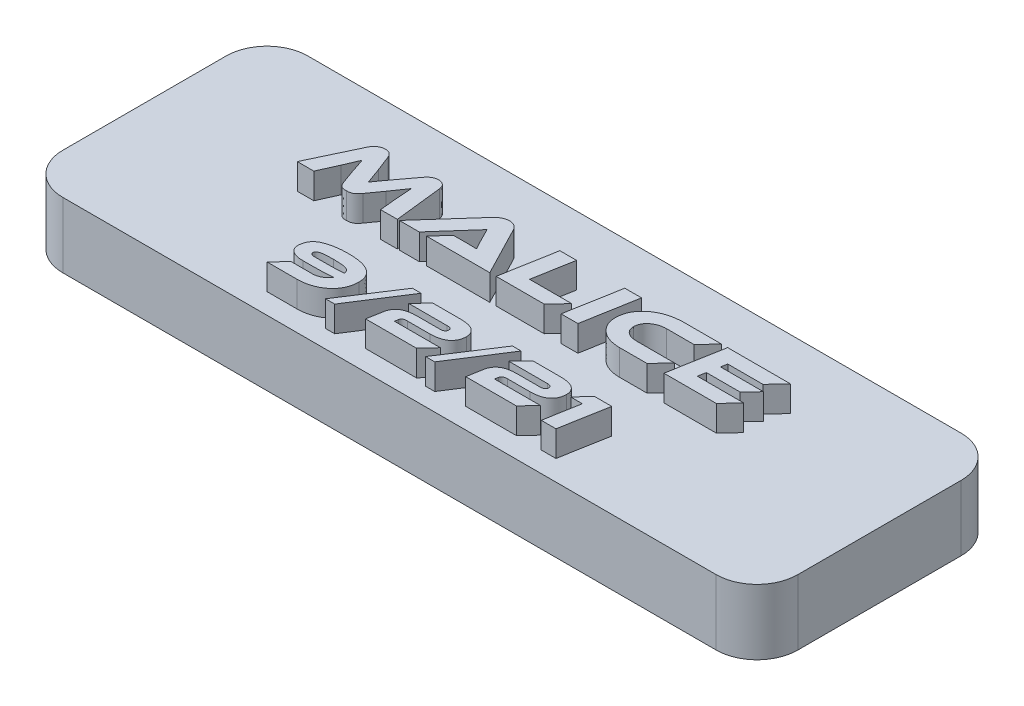
from build123d import *

# Parameters (mm, degrees)
SKETCH1_W           = 57.15
SKETCH1_H           = 19.05
BOSS_EXTRUDE1_DEPTH = 5.08
FILLET1_R           = 3.175
BOSS_EXTRUDE2_DEPTH = 2
SKETCH4_R           = 0.9
CUT_EXTRUDE1_DEPTH  = 4


with BuildPart() as part:
    # Sketch1 → Boss-Extrude1 (new body)
    with BuildSketch(Plane(origin=(0, 0, 0), x_dir=(1, 0, 0), z_dir=(0, 1, 0))):
        Rectangle(SKETCH1_W, SKETCH1_H)
    extrude(amount=BOSS_EXTRUDE1_DEPTH)

    # Fillet1
    fillet1_edges = [part.edges().sort_by_distance(p)[0] for p in [
        (-28.575, 2.54, -9.525),
        (-28.575, 2.54, 9.525),
        (28.575, 2.54, 9.525),
        (28.575, 2.54, -9.525),
    ]]
    fillet(fillet1_edges, radius=FILLET1_R)

    # Sketch3 → Boss-Extrude2 (add)
    with BuildSketch(Plane(origin=(0, 5.08, 0), x_dir=(1, 0, 0), z_dir=(0, 1, 0))):
        Polygon((13.310588964, 1.105536066), (13.411688748, 1.700326644), (16.015008189, 1.700326644), (16.924906246, 2.629107706), (13.582294634, 2.629107706), (13.670756945, 3.106887389), (16.406769853, 3.106887389), (17.449361376, 4.206347541), (12.55865932, 4.206347541), (11.806729675, 0.006075914), (15.875995986, 0.006075914), (16.912268773, 1.105536066), align=None)
        with BuildLine():
            add(Edge.make_bspline(
                [(8.559459744, 1.105536066), (8.519738714, 1.106368572), (8.442323233, 1.107991107), (8.329496145, 1.120099472), (8.223251152, 1.139341634), (8.122839563, 1.164731953), (8.028306652, 1.197730851), (7.93979656, 1.237674392), (7.857498969, 1.284870974), (7.781693666, 1.338214411), (7.714222428, 1.398892985), (7.654237259, 1.463686553), (7.603479599, 1.534061863), (7.560995817, 1.609307897), (7.528158823, 1.690172386), (7.504347011, 1.775740301), (7.48957339, 1.866215268), (7.486613584, 1.928202108), (7.485097778, 1.95994744)],
                knots=[0, 0, 0, 0, 0.000119146, 0.000232213, 0.000339979, 0.000442857, 0.0005426, 0.00063997, 0.000733741, 0.000826832, 0.000917476, 0.001005473, 0.001091233, 0.001177183, 0.0012641, 0.001352376, 0.001443149, 0.001538437, 0.001538437, 0.001538437, 0.001538437], degree=3))
            add(Edge.make_bspline(
                [(7.485097778, 1.95994744), (7.487475399, 2.00089212), (7.492159335, 2.08155355), (7.515918687, 2.199187811), (7.550399554, 2.311187764), (7.597375995, 2.41754111), (7.657504595, 2.517456178), (7.728928863, 2.612420697), (7.81409989, 2.700160835), (7.909460035, 2.782047564), (8.014487165, 2.855559397), (8.125969662, 2.920673089), (8.243882568, 2.975739929), (8.367493329, 3.021270473), (8.496953977, 3.058247704), (8.632457582, 3.084423964), (8.773965573, 3.10108536), (8.870301574, 3.104537604), (8.919406329, 3.106297295)],
                knots=[0, 0, 0, 0, 0.000122909, 0.000242131, 0.000358943, 0.000473945, 0.00058996, 0.00070807, 0.000829622, 0.000956043, 0.00108463, 0.001213669, 0.001342898, 0.001474501, 0.001608483, 0.001746351, 0.001888089, 0.00203545, 0.00203545, 0.00203545, 0.00203545], degree=3))
            Line((8.919406329, 3.106297295), (11.042723192, 3.106887389))
            Line((11.042723192, 3.106887389), (12.078995979, 4.206347541))
            Line((12.078995979, 4.206347541), (9.115508557, 4.206347541))
            add(Edge.make_bspline(
                [(9.115508557, 4.206347541), (9.013488767, 4.202700375), (8.813680891, 4.195557324), (8.520464977, 4.162353327), (8.240327871, 4.110015155), (7.973466922, 4.036172143), (7.718858162, 3.945267581), (7.477731511, 3.833094278), (7.249090222, 3.702119343), (7.070177689, 3.576781715), (6.934643749, 3.469194079), (6.840566124, 3.383435035), (6.751736583, 3.295964452), (6.668937448, 3.205335074), (6.593434551, 3.110727377), (6.522248768, 3.01426649), (6.459710324, 2.913020304), (6.401543861, 2.809716549), (6.350348537, 2.702914965), (6.306505274, 2.592415367), (6.268346866, 2.479140843), (6.23480376, 2.363167205), (6.209843716, 2.243547853), (6.189145543, 2.121372678), (6.176710882, 1.99550854), (6.17261647, 1.910604524), (6.170543478, 1.867617826)],
                knots=[0, 0, 0, 0, 0.000306166, 0.000599632, 0.000884344, 0.001160233, 0.001429449, 0.00169448, 0.001956971, 0.002218938, 0.002348999, 0.002475859, 0.002600617, 0.002722926, 0.00284385, 0.002963619, 0.003082322, 0.003200591, 0.003319167, 0.003437316, 0.003556997, 0.003677669, 0.003799234, 0.003923371, 0.004049262, 0.004178365, 0.004178365, 0.004178365, 0.004178365], degree=3))
            add(Edge.make_bspline(
                [(6.170543478, 1.867617826), (6.173543352, 1.801688472), (6.179448311, 1.671912941), (6.209898818, 1.482185543), (6.258551934, 1.301387781), (6.325358212, 1.130003576), (6.41036649, 0.967607666), (6.512900539, 0.814264123), (6.635152795, 0.671011828), (6.773384063, 0.536982875), (6.927640568, 0.415938203), (7.095199959, 0.308972587), (7.275905833, 0.218224767), (7.470135736, 0.144692398), (7.676305614, 0.084618858), (7.896140514, 0.042789332), (8.128208749, 0.013380635), (8.287632001, 0.00815489), (8.369085266, 0.005484928)],
                knots=[0, 0, 0, 0, 0.000197872, 0.000389491, 0.000575101, 0.000758611, 0.000940158, 0.001123976, 0.001310786, 0.001504088, 0.001700684, 0.001897981, 0.00209953, 0.002306142, 0.002520237, 0.002742905, 0.002976823, 0.003221191, 0.003221191, 0.003221191, 0.003221191], degree=3))
            Line((8.369085266, 0.005484928), (10.492993116, 0.006075914))
            Line((10.492993116, 0.006075914), (11.522947166, 1.105536066))
            Line((11.522947166, 1.105536066), (8.559459744, 1.105536066))
        make_face()
        Polygon((5.86396781, 4.208766837), (4.56230809, 4.208766837), (3.810378445, 0.003655726), (5.118356902, 0.003655726), align=None)
        Polygon((0.257455928, 1.105536066), (0.813504741, 4.208766837), (-0.48815498, 4.208766837), (-1.240084624, 0.006075914), (2.494288652, 0.006075914), (3.536880175, 1.105536066), align=None)
        with BuildLine():
            Line((-1.732130117, 0.006075914), (-3.697257171, 3.800574494))
            add(Edge.make_bspline(
                [(-3.697257171, 3.800574494), (-3.715378115, 3.832806008), (-3.751336779, 3.896765269), (-3.816210468, 3.985575321), (-3.893469955, 4.0630874), (-3.978372867, 4.133983071), (-4.076178761, 4.192399523), (-4.18828991, 4.23493807), (-4.314331738, 4.260058315), (-4.403062671, 4.264204191), (-4.449190386, 4.266359469)],
                knots=[0, 0, 0, 0, 0.000110886, 0.000220038, 0.000328642, 0.000438436, 0.000551159, 0.000668641, 0.000796469, 0.000934872, 0.000934872, 0.000934872, 0.000934872], degree=3))
            add(Edge.make_bspline(
                [(-4.449190386, 4.266359469), (-4.499002046, 4.264009128), (-4.595733167, 4.259444915), (-4.735771923, 4.230967468), (-4.866050485, 4.187726952), (-4.98578536, 4.126959855), (-5.095467016, 4.055096369), (-5.198668369, 3.977511138), (-5.292974582, 3.892229282), (-5.350357085, 3.830720556), (-5.378885604, 3.800140628)],
                knots=[0, 0, 0, 0, 0.00014941, 0.000290146, 0.000427171, 0.000560039, 0.000691642, 0.000820174, 0.000947034, 0.001072464, 0.001072464, 0.001072464, 0.001072464], degree=3))
            Line((-5.378885604, 3.800140628), (-8.76488385, 0.006075914))
            Line((-8.76488385, 0.006075914), (-7.216793406, 0.006075914))
            Line((-7.216793406, 0.006075914), (-4.739848695, 2.798493231))
            Line((-4.739848695, 2.798493231), (-4.177481146, 1.696826253))
            add(Edge.make_bspline(
                [(-4.177481146, 1.696826253), (-4.150807141, 1.644325557), (-4.096290894, 1.5370248), (-4.026862553, 1.403208105), (-3.970779459, 1.297464771), (-3.929638344, 1.223921613), (-3.893234503, 1.155498073), (-3.867936197, 1.112747401), (-3.855904058, 1.092414734)],
                knots=[0, 0, 0, 0, 0.000176664, 0.000361065, 0.000452265, 0.000535729, 0.000613867, 0.000684736, 0.000684736, 0.000684736, 0.000684736], degree=3))
            add(Edge.make_bspline(
                [(-3.855904058, 1.092414734), (-3.911352403, 1.095166522), (-4.029512238, 1.101030553), (-4.213942773, 1.103502684), (-4.408961639, 1.10564963), (-4.541214236, 1.105358474), (-4.60733913, 1.105212899)],
                knots=[0, 0, 0, 0, 0.000166537, 0.000354888, 0.000553268, 0.00075164, 0.00075164, 0.00075164, 0.00075164], degree=3))
            Line((-4.60733913, 1.105212899), (-5.662384225, 1.105536066))
            Line((-5.662384225, 1.105536066), (-6.64810712, 0.006075914))
            Line((-6.64810712, 0.006075914), (-1.732130117, 0.006075914))
        make_face()
        with BuildLine():
            add(Edge.make_bspline(
                [(-13.467536095, 3.821864298), (-13.481567467, 3.854947842), (-13.509019866, 3.919675843), (-13.563316131, 4.00785825), (-13.626848062, 4.084680144), (-13.699918016, 4.150072297), (-13.784786564, 4.202261522), (-13.881643932, 4.239681634), (-13.990489049, 4.261491707), (-14.066604539, 4.264690453), (-14.106319469, 4.266359469)],
                knots=[0, 0, 0, 0, 0.000107692, 0.0002107, 0.00030937, 0.000405859, 0.000503537, 0.000606581, 0.000715765, 0.000834889, 0.000834889, 0.000834889, 0.000834889], degree=3))
            add(Edge.make_bspline(
                [(-14.106319469, 4.266359469), (-14.147598246, 4.264911976), (-14.230109548, 4.262018611), (-14.351874754, 4.234270285), (-14.470276706, 4.188827027), (-14.584268314, 4.125361681), (-14.693404782, 4.045413244), (-14.79022222, 3.943118147), (-14.880285745, 3.825335584), (-14.928160308, 3.735707046), (-14.952826618, 3.689527923)],
                knots=[0, 0, 0, 0, 0.000123685, 0.000247231, 0.000372524, 0.000503046, 0.00063761, 0.000776601, 0.000924145, 0.00108096, 0.00108096, 0.00108096, 0.00108096], degree=3))
            Line((-14.952826618, 3.689527923), (-16.69641045, 0.003655726))
            Line((-16.69641045, 0.003655726), (-15.413706939, 0.003655726))
            Line((-15.413706939, 0.003655726), (-14.756558342, 1.464481009))
            add(Edge.make_bspline(
                [(-14.756558342, 1.464481009), (-14.732328584, 1.519909601), (-14.684700559, 1.628864646), (-14.615829165, 1.789446184), (-14.548558078, 1.942964846), (-14.485802871, 2.090413825), (-14.425225209, 2.230959426), (-14.368533112, 2.365338229), (-14.315652855, 2.493505747), (-14.281234059, 2.576699716), (-14.264468213, 2.617224589)],
                knots=[0, 0, 0, 0, 0.000181479, 0.000356729, 0.00052418, 0.000684305, 0.000837469, 0.000983313, 0.001121843, 0.001253412, 0.001253412, 0.001253412, 0.001253412], degree=3))
            add(Edge.make_bspline(
                [(-14.264468213, 2.617224589), (-14.254223496, 2.582146896), (-14.232980976, 2.509412955), (-14.197608459, 2.396952832), (-14.1608843, 2.276154433), (-14.11754915, 2.146346616), (-14.069664633, 2.002632754), (-14.013586346, 1.841123618), (-13.948445598, 1.659810645), (-13.902744775, 1.531826555), (-13.878694976, 1.464475652)],
                knots=[0, 0, 0, 0, 0.000109626, 0.000227311, 0.000353666, 0.000488379, 0.000637834, 0.000808115, 0.001001264, 0.001215812, 0.001215812, 0.001215812, 0.001215812], degree=3))
            Line((-13.878694976, 1.464475652), (-13.499129777, 0.404912456))
            add(Edge.make_bspline(
                [(-13.499129777, 0.404912456), (-13.480955071, 0.359535583), (-13.446999655, 0.27475894), (-13.381034656, 0.165066891), (-13.309736025, 0.079389949), (-13.228674603, 0.020148619), (-13.140153659, -0.017188774), (-13.044819996, -0.042938659), (-12.940255221, -0.056575195), (-12.867674832, -0.05604004), (-12.830159662, -0.05576343)],
                knots=[0, 0, 0, 0, 0.000146435, 0.000273581, 0.000382454, 0.000478632, 0.000571543, 0.000669118, 0.00077423, 0.000886686, 0.000886686, 0.000886686, 0.000886686], degree=3))
            add(Edge.make_bspline(
                [(-12.830159662, -0.05576343), (-12.79234346, -0.055992745), (-12.717953486, -0.056443841), (-12.608524296, -0.042717291), (-12.504410842, -0.015563104), (-12.40234571, 0.022829401), (-12.301161744, 0.083036928), (-12.199938757, 0.169070984), (-12.095485911, 0.280708265), (-12.030314945, 0.367692811), (-11.995536522, 0.414112029)],
                knots=[0, 0, 0, 0, 0.00011337, 0.000223015, 0.000329662, 0.000435594, 0.000549104, 0.000680897, 0.00083287, 0.001006773, 0.001006773, 0.001006773, 0.001006773], degree=3))
            Line((-11.995536522, 0.414112029), (-11.243340844, 1.465200548))
            add(Edge.make_bspline(
                [(-11.243340844, 1.465200548), (-11.197158545, 1.529169794), (-11.108760313, 1.651614289), (-10.983975191, 1.828381807), (-10.87026189, 1.987679293), (-10.769702216, 2.133154937), (-10.677873961, 2.266547935), (-10.593187076, 2.390994455), (-10.515053641, 2.508743118), (-10.465493601, 2.584889894), (-10.44147372, 2.621795362)],
                knots=[0, 0, 0, 0, 0.000236691, 0.000453055, 0.000649121, 0.000823842, 0.000983589, 0.001134958, 0.00127542, 0.001407521, 0.001407521, 0.001407521, 0.001407521], degree=3))
            add(Edge.make_bspline(
                [(-10.44147372, 2.621795362), (-10.439239748, 2.536757041), (-10.434648993, 2.362005428), (-10.420608478, 2.139966033), (-10.407941006, 1.952236415), (-10.394363366, 1.800289613), (-10.381181024, 1.638717755), (-10.370888112, 1.52784762), (-10.365598889, 1.470874734)],
                knots=[0, 0, 0, 0, 0.000255182, 0.000524392, 0.000667354, 0.000819643, 0.000982028, 0.00115368, 0.00115368, 0.00115368, 0.00115368], degree=3))
            Line((-10.365598889, 1.470874734), (-10.21970553, 0.003655726))
            Line((-10.21970553, 0.003655726), (-8.918045809, 0.003655726))
            Line((-8.918045809, 0.003655726), (-9.335082419, 3.690201933))
            add(Edge.make_bspline(
                [(-9.335082419, 3.690201933), (-9.342447817, 3.735767572), (-9.3565213, 3.822832418), (-9.401368118, 3.942054526), (-9.460350308, 4.044898175), (-9.539381431, 4.125995793), (-9.629654398, 4.189905999), (-9.731208732, 4.235155569), (-9.843090231, 4.262540065), (-9.921157798, 4.265057293), (-9.96154256, 4.266359469)],
                knots=[0, 0, 0, 0, 0.000138154, 0.000263979, 0.000379994, 0.000491206, 0.000600771, 0.000710019, 0.000822876, 0.000943824, 0.000943824, 0.000943824, 0.000943824], degree=3))
            add(Edge.make_bspline(
                [(-9.96154256, 4.266359469), (-10.003388066, 4.264315029), (-10.085262157, 4.26031492), (-10.204189641, 4.237458819), (-10.315093823, 4.198932407), (-10.417114704, 4.144580626), (-10.512700273, 4.0797862), (-10.600183003, 4.002630646), (-10.683891156, 3.917859546), (-10.732264048, 3.853756483), (-10.756857053, 3.821166184)],
                knots=[0, 0, 0, 0, 0.000125572, 0.000245692, 0.000361916, 0.000476404, 0.000591519, 0.00070753, 0.000825838, 0.000948192, 0.000948192, 0.000948192, 0.000948192], degree=3))
            Line((-10.756857053, 3.821166184), (-11.647739981, 2.63063338))
            add(Edge.make_bspline(
                [(-11.647739981, 2.63063338), (-11.676832204, 2.592038973), (-11.733437576, 2.516944994), (-11.81579065, 2.40752977), (-11.892319929, 2.303579542), (-11.965872566, 2.207146967), (-12.033610423, 2.115786728), (-12.095293615, 2.029366729), (-12.154034616, 1.950451781), (-12.22360065, 1.854220433), (-12.303480982, 1.742020151), (-12.392133912, 1.614517972), (-12.471621427, 1.49522478), (-12.5218235, 1.418793145), (-12.545857585, 1.382201739)],
                knots=[0, 0, 0, 0, 0.000144993, 0.000282116, 0.00041083, 0.000532231, 0.000645954, 0.000752012, 0.000850745, 0.000941075, 0.001108235, 0.001263934, 0.001406932, 0.001538268, 0.001538268, 0.001538268, 0.001538268], degree=3))
            add(Edge.make_bspline(
                [(-12.545857585, 1.382201739), (-12.557934897, 1.418805813), (-12.583660775, 1.496776135), (-12.626893043, 1.619692211), (-12.675221374, 1.756361741), (-12.730447309, 1.906038253), (-12.790476038, 2.069898911), (-12.857396403, 2.24675863), (-12.929521666, 2.43736016), (-12.98029604, 2.568503977), (-13.006591498, 2.636421836)],
                knots=[0, 0, 0, 0, 0.000115632, 0.000246309, 0.000390878, 0.000550518, 0.00072492, 0.000914406, 0.001117803, 0.001336294, 0.001336294, 0.001336294, 0.001336294], degree=3))
            Line((-13.006591498, 2.636421836), (-13.467536095, 3.821864298))
        make_face()
        Polygon((9.787635139, -5.218973535), (10.688844934, -5.218973535), (10.207831117, -7.93430124), (11.352312267, -7.93430124), (12.010250706, -4.256945902), (10.655671567, -4.256945902), align=None)
        with BuildLine():
            Line((4.971026026, -5.218973535), (7.96215792, -5.218973535))
            add(Edge.make_bspline(
                [(7.96215792, -5.218973535), (7.989858834, -5.218922741), (8.041705209, -5.218827674), (8.114434212, -5.225918073), (8.175958254, -5.242216387), (8.22778879, -5.26353583), (8.26788218, -5.294908436), (8.296196179, -5.334273792), (8.313748157, -5.381008794), (8.314972856, -5.4147712), (8.315607222, -5.432259348)],
                knots=[0, 0, 0, 0, 8.3099e-05, 0.000155531, 0.000218392, 0.000273538, 0.000322508, 0.000368908, 0.000417497, 0.000469711, 0.000469711, 0.000469711, 0.000469711], degree=3))
            add(Edge.make_bspline(
                [(8.315607222, -5.432259348), (8.314967429, -5.458018948), (8.313757824, -5.506720508), (8.293195439, -5.573936821), (8.259909062, -5.630194031), (8.210695439, -5.673414306), (8.14716434, -5.704561408), (8.069430174, -5.726311626), (7.976305014, -5.738498194), (7.90930337, -5.73961472), (7.87327067, -5.740215175)],
                knots=[0, 0, 0, 0, 7.6993e-05, 0.000145564, 0.000208395, 0.000270703, 0.000339032, 0.00041902, 0.000511893, 0.000619952, 0.000619952, 0.000619952, 0.000619952], degree=3))
            Line((7.87327067, -5.740215175), (6.115507176, -5.739416071))
            add(Edge.make_bspline(
                [(6.115507176, -5.739416071), (6.05990502, -5.740560639), (5.951651858, -5.742789025), (5.793656532, -5.753609346), (5.644937172, -5.772857955), (5.505314304, -5.798779792), (5.375051106, -5.833149331), (5.253972254, -5.875619954), (5.141704874, -5.92500466), (5.038503006, -5.98174212), (4.945033809, -6.047028209), (4.860508316, -6.120143527), (4.785107707, -6.201107035), (4.719106685, -6.289606037), (4.662725112, -6.385733808), (4.615629357, -6.489539314), (4.576681994, -6.600822081), (4.559360318, -6.678800473), (4.550547277, -6.718474855)],
                knots=[0, 0, 0, 0, 0.000166829, 0.000324804, 0.000474816, 0.000616477, 0.000750546, 0.000878553, 0.001001026, 0.001118108, 0.001231277, 0.001342418, 0.001452782, 0.001562526, 0.00167296, 0.001786425, 0.001904052, 0.002025887, 0.002025887, 0.002025887, 0.002025887], degree=3))
            Line((4.550547277, -6.718474855), (4.335203165, -7.932183575))
            Line((4.335203165, -7.932183575), (8.271776009, -7.932183575))
            Line((8.271776009, -7.932183575), (9.178514698, -6.970155942))
            Line((9.178514698, -6.970155942), (5.606848887, -6.970155942))
            Line((5.606848887, -6.970155942), (5.656608937, -6.707239748))
            add(Edge.make_bspline(
                [(5.656608937, -6.707239748), (5.660386461, -6.686112106), (5.667709218, -6.645156023), (5.696420571, -6.590591717), (5.734781264, -6.543848716), (5.786120596, -6.508043577), (5.847196062, -6.47963759), (5.919513682, -6.461031101), (6.002577104, -6.450993538), (6.061500614, -6.450679637), (6.092726069, -6.450513291)],
                knots=[0, 0, 0, 0, 6.4036e-05, 0.000124134, 0.000182613, 0.000243892, 0.000310094, 0.000383827, 0.000466868, 0.000560486, 0.000560486, 0.000560486, 0.000560486], degree=3))
            Line((6.092726069, -6.450513291), (7.851580032, -6.449714187))
            add(Edge.make_bspline(
                [(7.851580032, -6.449714187), (7.917261057, -6.448593152), (8.044595497, -6.446419826), (8.228493346, -6.426694059), (8.399909956, -6.400940141), (8.557756843, -6.361961645), (8.703510836, -6.315052912), (8.834852091, -6.255202462), (8.954325207, -6.187512089), (9.059037646, -6.107690588), (9.151620838, -6.020066732), (9.2320772, -5.925525662), (9.299856084, -5.823724541), (9.355608886, -5.715194429), (9.397744856, -5.599220599), (9.428440292, -5.476792913), (9.446095637, -5.347458364), (9.44804859, -5.259004345), (9.449044644, -5.21389067)],
                knots=[0, 0, 0, 0, 0.00019697, 0.000381861, 0.000554393, 0.000716581, 0.000869107, 0.001013024, 0.00114885, 0.001280192, 0.001406932, 0.001530654, 0.001651783, 0.001773055, 0.001895792, 0.002021116, 0.002151095, 0.002286391, 0.002286391, 0.002286391, 0.002286391], degree=3))
            add(Edge.make_bspline(
                [(9.449044644, -5.21389067), (9.448592189, -5.1780961), (9.447706444, -5.108023129), (9.431496597, -5.005989197), (9.407504524, -4.909275966), (9.370969821, -4.818686266), (9.323335469, -4.734234215), (9.265256427, -4.655338408), (9.1968888, -4.582231577), (9.11759436, -4.515185386), (9.026771443, -4.455053695), (8.923192822, -4.402688892), (8.806959702, -4.359688685), (8.678772223, -4.322394884), (8.537969214, -4.294289614), (8.384622168, -4.27367202), (8.218755637, -4.26108405), (8.103926021, -4.258543735), (8.044446117, -4.257227893)],
                knots=[0, 0, 0, 0, 0.000107259, 0.000209975, 0.000309113, 0.00040566, 0.000501999, 0.00059927, 0.000698874, 0.0008016, 0.000910084, 0.001024914, 0.001148961, 0.001281358, 0.001425053, 0.00157924, 0.00174531, 0.001923772, 0.001923772, 0.001923772, 0.001923772], degree=3))
            Line((8.044446117, -4.257227893), (5.877764715, -4.256945902))
            Line((5.877764715, -4.256945902), (4.971026026, -5.218973535))
        make_face()
        Polygon((4.085215586, -4.05005839), (1.420288464, -8.139071868), (2.133515847, -8.139071868), (4.759740708, -4.05005839), align=None)
        with BuildLine():
            Line((-2.810257838, -5.218973535), (0.180874056, -5.218973535))
            add(Edge.make_bspline(
                [(0.180874056, -5.218973535), (0.20857497, -5.218922741), (0.260421344, -5.218827674), (0.333150347, -5.225918073), (0.394674389, -5.242216387), (0.446504926, -5.26353583), (0.486598315, -5.294908436), (0.514912315, -5.334273792), (0.532464292, -5.381008794), (0.533688991, -5.4147712), (0.534323357, -5.432259348)],
                knots=[0, 0, 0, 0, 8.3099e-05, 0.000155531, 0.000218392, 0.000273538, 0.000322508, 0.000368908, 0.000417497, 0.000469711, 0.000469711, 0.000469711, 0.000469711], degree=3))
            add(Edge.make_bspline(
                [(0.534323357, -5.432259348), (0.533683564, -5.458018948), (0.532473959, -5.506720508), (0.511911574, -5.573936821), (0.478625198, -5.630194031), (0.429411574, -5.673414306), (0.365880476, -5.704561408), (0.288146309, -5.726311626), (0.195021149, -5.738498194), (0.128019505, -5.73961472), (0.091986806, -5.740215175)],
                knots=[0, 0, 0, 0, 7.6993e-05, 0.000145564, 0.000208395, 0.000270703, 0.000339032, 0.00041902, 0.000511893, 0.000619952, 0.000619952, 0.000619952, 0.000619952], degree=3))
            Line((0.091986806, -5.740215175), (-1.665776689, -5.739416071))
            add(Edge.make_bspline(
                [(-1.665776689, -5.739416071), (-1.721378845, -5.740560639), (-1.829632007, -5.742789025), (-1.987627333, -5.753609346), (-2.136346693, -5.772857955), (-2.275969561, -5.798779792), (-2.406232759, -5.833149331), (-2.527311611, -5.875619954), (-2.639578991, -5.92500466), (-2.742780859, -5.98174212), (-2.836250055, -6.047028209), (-2.920775548, -6.120143527), (-2.996176157, -6.201107035), (-3.06217718, -6.289606037), (-3.118558753, -6.385733808), (-3.165654508, -6.489539314), (-3.204601871, -6.600822081), (-3.221923547, -6.678800473), (-3.230736588, -6.718474855)],
                knots=[0, 0, 0, 0, 0.000166829, 0.000324804, 0.000474816, 0.000616477, 0.000750546, 0.000878553, 0.001001026, 0.001118108, 0.001231277, 0.001342418, 0.001452782, 0.001562526, 0.00167296, 0.001786425, 0.001904052, 0.002025887, 0.002025887, 0.002025887, 0.002025887], degree=3))
            Line((-3.230736588, -6.718474855), (-3.4460807, -7.932183575))
            Line((-3.4460807, -7.932183575), (0.490492145, -7.932183575))
            Line((0.490492145, -7.932183575), (1.397230833, -6.970155942))
            Line((1.397230833, -6.970155942), (-2.174434977, -6.970155942))
            Line((-2.174434977, -6.970155942), (-2.124674927, -6.707239748))
            add(Edge.make_bspline(
                [(-2.124674927, -6.707239748), (-2.120897404, -6.686112106), (-2.113574647, -6.645156023), (-2.084863294, -6.590591717), (-2.046502601, -6.543848716), (-1.995163269, -6.508043577), (-1.934087802, -6.47963759), (-1.861770182, -6.461031101), (-1.778706761, -6.450993538), (-1.719783251, -6.450679637), (-1.688557796, -6.450513291)],
                knots=[0, 0, 0, 0, 6.4036e-05, 0.000124134, 0.000182613, 0.000243892, 0.000310094, 0.000383827, 0.000466868, 0.000560486, 0.000560486, 0.000560486, 0.000560486], degree=3))
            Line((-1.688557796, -6.450513291), (0.070296167, -6.449714187))
            add(Edge.make_bspline(
                [(0.070296167, -6.449714187), (0.135977192, -6.448593152), (0.263311632, -6.446419826), (0.447209481, -6.426694059), (0.618626092, -6.400940141), (0.776472978, -6.361961645), (0.922226971, -6.315052912), (1.053568226, -6.255202462), (1.173041342, -6.187512089), (1.277753781, -6.107690588), (1.370336973, -6.020066732), (1.450793335, -5.925525662), (1.51857222, -5.823724541), (1.574325021, -5.715194429), (1.616460991, -5.599220599), (1.647156427, -5.476792913), (1.664811772, -5.347458364), (1.666764726, -5.259004345), (1.667760779, -5.21389067)],
                knots=[0, 0, 0, 0, 0.00019697, 0.000381861, 0.000554393, 0.000716581, 0.000869107, 0.001013024, 0.00114885, 0.001280192, 0.001406932, 0.001530654, 0.001651783, 0.001773055, 0.001895792, 0.002021116, 0.002151095, 0.002286391, 0.002286391, 0.002286391, 0.002286391], degree=3))
            add(Edge.make_bspline(
                [(1.667760779, -5.21389067), (1.667308324, -5.1780961), (1.66642258, -5.108023129), (1.650212732, -5.005989197), (1.62622066, -4.909275966), (1.589685957, -4.818686266), (1.542051604, -4.734234215), (1.483972562, -4.655338408), (1.415604935, -4.582231577), (1.336310495, -4.515185386), (1.245487578, -4.455053695), (1.141908957, -4.402688892), (1.025675837, -4.359688685), (0.897488358, -4.322394884), (0.756685349, -4.294289614), (0.603338303, -4.27367202), (0.437471772, -4.26108405), (0.322642157, -4.258543735), (0.263162252, -4.257227893)],
                knots=[0, 0, 0, 0, 0.000107259, 0.000209975, 0.000309113, 0.00040566, 0.000501999, 0.00059927, 0.000698874, 0.0008016, 0.000910084, 0.001024914, 0.001148961, 0.001281358, 0.001425053, 0.00157924, 0.00174531, 0.001923772, 0.001923772, 0.001923772, 0.001923772], degree=3))
            Line((0.263162252, -4.257227893), (-1.90351915, -4.256945902))
            Line((-1.90351915, -4.256945902), (-2.810257838, -5.218973535))
        make_face()
        Polygon((-3.696068279, -4.05005839), (-6.360995401, -8.139071868), (-5.647768018, -8.139071868), (-3.021543157, -4.05005839), align=None)
        with BuildLine():
            Line((-10.210967386, -6.970155942), (-11.106223347, -7.932183575))
            Line((-11.106223347, -7.932183575), (-8.788045706, -7.932183575))
            add(Edge.make_bspline(
                [(-8.788045706, -7.932183575), (-8.69819945, -7.929777147), (-8.521629747, -7.92504793), (-8.262618883, -7.89377972), (-8.014579552, -7.845456505), (-7.778091238, -7.778119368), (-7.552818438, -7.693257531), (-7.339141967, -7.589683886), (-7.137058519, -7.467776465), (-6.978877458, -7.351552012), (-6.859642166, -7.251102183), (-6.776292377, -7.171271707), (-6.697767358, -7.089073015), (-6.62455217, -7.003301544), (-6.557812715, -6.913691428), (-6.495478729, -6.821436558), (-6.439917258, -6.725101624), (-6.388262601, -6.626227548), (-6.343603186, -6.523415525), (-6.304432245, -6.417304195), (-6.269792149, -6.308297587), (-6.242188258, -6.195383605), (-6.218437058, -6.079711014), (-6.202391353, -5.960192069), (-6.189753448, -5.837767761), (-6.18640552, -5.75491021), (-6.184712874, -5.713019076)],
                knots=[0, 0, 0, 0, 0.000269512, 0.000529657, 0.000781592, 0.001026938, 0.001266417, 0.001502887, 0.001738287, 0.001973466, 0.00209094, 0.002205793, 0.002319514, 0.002431869, 0.002543853, 0.002654555, 0.002765679, 0.002877297, 0.002989052, 0.003101677, 0.003216532, 0.003331962, 0.003450243, 0.003570604, 0.003693573, 0.003819318, 0.003819318, 0.003819318, 0.003819318], degree=3))
            add(Edge.make_bspline(
                [(-6.184712874, -5.713019076), (-6.186837994, -5.652117472), (-6.190971785, -5.533651456), (-6.219360412, -5.361744864), (-6.265649193, -5.20161806), (-6.329870477, -5.05300733), (-6.41248814, -4.916595218), (-6.51201648, -4.79126316), (-6.631717241, -4.67984859), (-6.767171528, -4.578328397), (-6.921874012, -4.490460709), (-7.093608153, -4.413762538), (-7.283287983, -4.349318484), (-7.490351959, -4.296844754), (-7.715212925, -4.256528236), (-7.957722635, -4.227593809), (-8.217984021, -4.208531898), (-8.397426495, -4.206884801), (-8.48998221, -4.206035236)],
                knots=[0, 0, 0, 0, 0.00018267, 0.00035533, 0.000521131, 0.000681619, 0.000839513, 0.000998287, 0.001160113, 0.00132873, 0.001505033, 0.001692644, 0.001892226, 0.002105242, 0.002332894, 0.00257706, 0.002837673, 0.00311529, 0.00311529, 0.00311529, 0.00311529], degree=3))
            add(Edge.make_bspline(
                [(-8.48998221, -4.206035236), (-8.573181065, -4.205592276), (-8.736719893, -4.204721577), (-8.977958515, -4.215578286), (-9.210779343, -4.234927868), (-9.435205495, -4.265660573), (-9.651352794, -4.305110003), (-9.858774336, -4.355643498), (-10.057694543, -4.415783415), (-10.21713906, -4.473503284), (-10.338999278, -4.525130752), (-10.423465623, -4.569635858), (-10.5034733, -4.616422557), (-10.576680329, -4.668834502), (-10.645559866, -4.723868288), (-10.707768155, -4.784450305), (-10.765735919, -4.847987079), (-10.817100975, -4.916899938), (-10.863482561, -4.989145242), (-10.90366342, -5.066161285), (-10.938905814, -5.146801308), (-10.968470921, -5.2318633), (-10.992474941, -5.32088445), (-11.01074047, -5.41389817), (-11.023764083, -5.510872203), (-11.027644422, -5.57700115), (-11.029617929, -5.610633762)],
                knots=[0, 0, 0, 0, 0.000249565, 0.000490555, 0.000724179, 0.0009502, 0.001169841, 0.001383052, 0.001590297, 0.00179299, 0.001891509, 0.001987031, 0.002079216, 0.002169319, 0.002256891, 0.002343445, 0.002429536, 0.002514644, 0.002600961, 0.002686833, 0.002774954, 0.002864759, 0.002956732, 0.003051325, 0.003148954, 0.003249996, 0.003249996, 0.003249996, 0.003249996], degree=3))
            add(Edge.make_bspline(
                [(-11.029617929, -5.610633762), (-11.028183075, -5.643753438), (-11.025377578, -5.708510641), (-11.009496184, -5.802650158), (-10.98250877, -5.890402518), (-10.947705553, -5.972873051), (-10.901588171, -6.048807605), (-10.845023821, -6.117637999), (-10.779412728, -6.18094304), (-10.703948227, -6.237416652), (-10.619982166, -6.287658407), (-10.527956214, -6.330947125), (-10.428349821, -6.367615523), (-10.320911026, -6.398128227), (-10.20553594, -6.420818141), (-10.08267712, -6.437537883), (-9.952350263, -6.448004733), (-9.862871679, -6.449663014), (-9.816991866, -6.450513291)],
                knots=[0, 0, 0, 0, 9.9392e-05, 0.000194336, 0.000285432, 0.000374287, 0.00046222, 0.000550917, 0.000640864, 0.000735091, 0.000833037, 0.000933937, 0.001039728, 0.001151139, 0.001268635, 0.001392165, 0.00152296, 0.001660599, 0.001660599, 0.001660599, 0.001660599], degree=3))
            add(Edge.make_bspline(
                [(-9.816991866, -6.450513291), (-9.76339936, -6.450588766), (-9.658613318, -6.450736339), (-9.505036616, -6.449683936), (-9.3581243, -6.448934551), (-9.218144089, -6.448155746), (-9.0848308, -6.447263447), (-8.958443121, -6.446777451), (-8.838732197, -6.444902162), (-8.725680292, -6.443402764), (-8.619565019, -6.441665317), (-8.52036352, -6.440519694), (-8.42787044, -6.437415789), (-8.342254422, -6.436504009), (-8.263344993, -6.433778787), (-8.191358703, -6.43134803), (-8.126001976, -6.429349577), (-8.049261585, -6.424605461), (-7.962003184, -6.420771207), (-7.864734759, -6.413793257), (-7.776135406, -6.408049685), (-7.696261488, -6.400065169), (-7.62487582, -6.394706302), (-7.56258455, -6.386176476), (-7.508923422, -6.378534723), (-7.476245457, -6.372485855), (-7.461329758, -6.369724879)],
                knots=[0, 0, 0, 0, 0.000160777, 0.000314357, 0.000460738, 0.00060152, 0.000734304, 0.000860688, 0.000980681, 0.001093477, 0.001199873, 0.001299072, 0.00139109, 0.001477493, 0.001555918, 0.001627948, 0.001693582, 0.001752061, 0.001858593, 0.001955591, 0.002044608, 0.00212492, 0.002196397, 0.002259299, 0.002313485, 0.002358987, 0.002358987, 0.002358987, 0.002358987], degree=3))
            add(Edge.make_bspline(
                [(-7.461329758, -6.369724879), (-7.491050815, -6.410755391), (-7.550896087, -6.493372984), (-7.658590188, -6.604032197), (-7.778514282, -6.70577684), (-7.889057245, -6.780745718), (-7.984013287, -6.833676621), (-8.05881304, -6.868964979), (-8.136053494, -6.899761591), (-8.216945413, -6.923136897), (-8.300021594, -6.943784293), (-8.386739007, -6.957621584), (-8.476155945, -6.967749518), (-8.536880058, -6.969535864), (-8.567571081, -6.970438714)],
                knots=[0, 0, 0, 0, 0.000151822, 0.000305704, 0.000461788, 0.000623076, 0.000705429, 0.000787724, 0.000871054, 0.000954565, 0.001040123, 0.001127702, 0.001217802, 0.001309875, 0.001309875, 0.001309875, 0.001309875], degree=3))
            Line((-8.567571081, -6.970438714), (-10.210967386, -6.970155942))
        make_face()
        with BuildLine():
            add(Edge.make_bspline(
                [(-9.60079319, -5.739416071), (-9.629178208, -5.739333167), (-9.682366922, -5.739177819), (-9.756117251, -5.728388524), (-9.819004655, -5.712937853), (-9.8709278, -5.691097621), (-9.912047035, -5.66209877), (-9.940261775, -5.625127048), (-9.958394063, -5.582069955), (-9.95956476, -5.550830586), (-9.960171329, -5.534644662)],
                knots=[0, 0, 0, 0, 8.5051e-05, 0.000159372, 0.000223007, 0.000278884, 0.00032752, 0.000371998, 0.000416856, 0.000465088, 0.000465088, 0.000465088, 0.000465088], degree=3))
            add(Edge.make_bspline(
                [(-9.960171329, -5.534644662), (-9.961373614, -5.520492659), (-9.96372754, -5.492784798), (-9.955780866, -5.451904192), (-9.940500977, -5.413284736), (-9.915586643, -5.377865243), (-9.88329964, -5.344746874), (-9.842034736, -5.315137149), (-9.79340632, -5.287204256), (-9.734922618, -5.262102266), (-9.664427673, -5.239181686), (-9.578288785, -5.220969825), (-9.476346652, -5.204302076), (-9.35807506, -5.19102051), (-9.223607236, -5.180808804), (-9.072616072, -5.174134861), (-8.905423457, -5.169033665), (-8.78861062, -5.168550026), (-8.727548134, -5.16829721)],
                knots=[0, 0, 0, 0, 4.2424e-05, 8.3061e-05, 0.000123611, 0.000166209, 0.000212026, 0.00026178, 0.000318034, 0.000380003, 0.000452348, 0.000540062, 0.000643816, 0.000762183, 0.000896965, 0.001048315, 0.00121556, 0.00139874, 0.00139874, 0.00139874, 0.00139874], degree=3))
            add(Edge.make_bspline(
                [(-8.727548134, -5.16829721), (-8.675021605, -5.167787601), (-8.57289569, -5.166796781), (-8.424350892, -5.169363834), (-8.285070795, -5.174373781), (-8.155244416, -5.184530804), (-8.034548145, -5.195834798), (-7.923165517, -5.211544935), (-7.821425998, -5.232098586), (-7.728213049, -5.253456427), (-7.64459229, -5.280784321), (-7.571102335, -5.316195779), (-7.508460023, -5.359607715), (-7.454891789, -5.409671023), (-7.413150772, -5.468468051), (-7.38029612, -5.534032814), (-7.359849283, -5.607713922), (-7.35396732, -5.659314386), (-7.350945592, -5.685822977)],
                knots=[0, 0, 0, 0, 0.000157579, 0.000306377, 0.00044567, 0.000575606, 0.000696984, 0.000809313, 0.000912848, 0.001008299, 0.001096072, 0.001176204, 0.001252088, 0.00132394, 0.001394981, 0.001467241, 0.001542944, 0.00162292, 0.00162292, 0.00162292, 0.00162292], degree=3))
            add(Edge.make_bspline(
                [(-7.350945592, -5.685822977), (-7.368536296, -5.688016622), (-7.406083761, -5.692698971), (-7.465840846, -5.698817251), (-7.53241564, -5.705774202), (-7.605842709, -5.709867374), (-7.685818465, -5.714809123), (-7.772455017, -5.719762177), (-7.865785778, -5.723691176), (-7.968985382, -5.726773296), (-8.088155241, -5.730355113), (-8.229752253, -5.73231403), (-8.396659638, -5.734779827), (-8.588629132, -5.737306699), (-8.805934607, -5.738848781), (-9.048568895, -5.739352636), (-9.316529524, -5.740463735), (-9.503436706, -5.740300435), (-9.60079319, -5.739416071)],
                knots=[0, 0, 0, 0, 5.3179e-05, 0.000113511, 0.000180209, 0.000253954, 0.000334087, 0.000420608, 0.00051428, 0.000614317, 0.000730344, 0.000871944, 0.001039137, 0.001231125, 0.0014479, 0.001691066, 0.001959029, 0.002251787, 0.002251787, 0.002251787, 0.002251787], degree=3))
        make_face(mode=Mode.SUBTRACT)
    extrude(amount=BOSS_EXTRUDE2_DEPTH)

    # Sketch4 → Cut-Extrude1 (cut)
    with BuildSketch(Plane.XZ):
        with Locations((-25.4, 0)):
            Circle(SKETCH4_R)
        with Locations((25.4, 0)):
            Circle(SKETCH4_R)
    extrude(amount=-CUT_EXTRUDE1_DEPTH, mode=Mode.SUBTRACT)


solid = part.part
